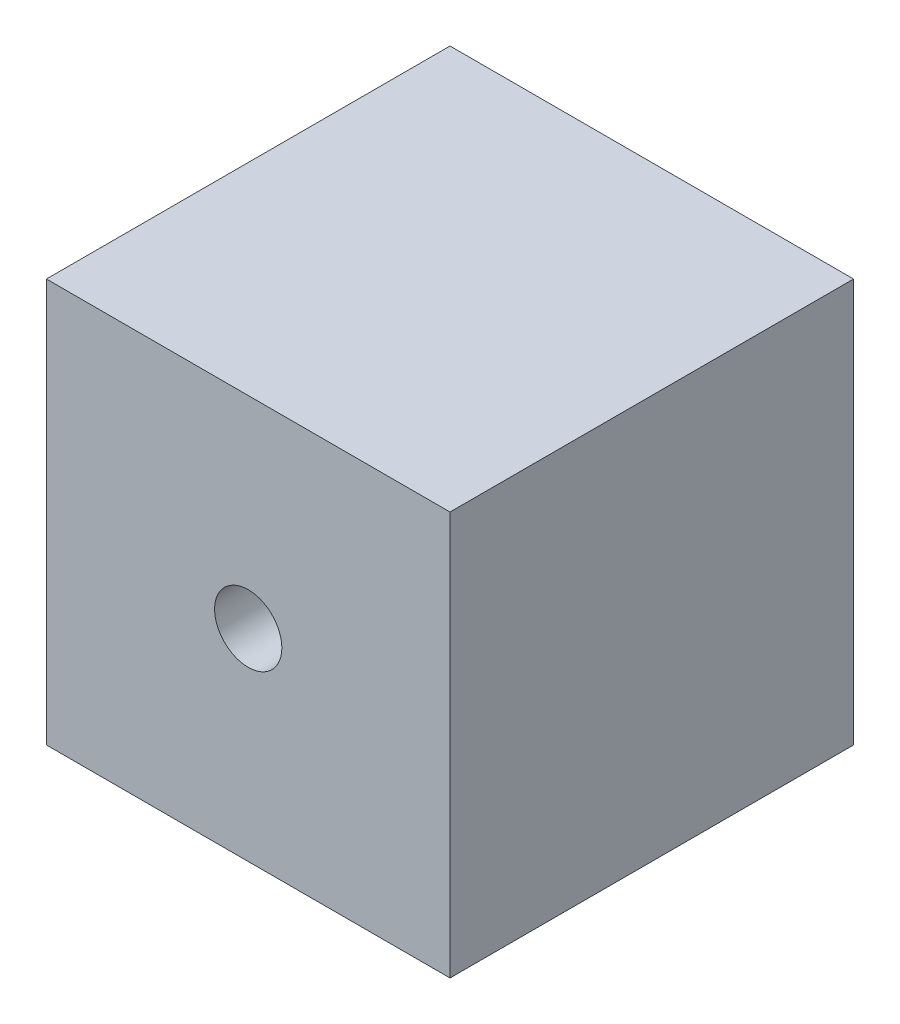
from build123d import *

# Parameters (mm, degrees)
SKETCH2_W           = 30
SKETCH2_H           = 30
BOSS_EXTRUDE1_DEPTH = 15
SKETCH3_R           = 2.5
CUT_EXTRUDE1_DEPTH  = 5


with BuildPart() as part:
    # Sketch2 → Boss-Extrude1 (new body, symmetric)
    with BuildSketch(Plane(origin=(0, 0, 0), x_dir=(0, 0, -1), z_dir=(1, 0, 0))):
        with Locations((15, 15)):
            Rectangle(SKETCH2_W, SKETCH2_H)
    extrude(amount=BOSS_EXTRUDE1_DEPTH, both=True)

    # Sketch3 → Cut-Extrude1 (cut, symmetric)
    with BuildSketch(Plane.XY):
        with Locations((0, 15)):
            Circle(SKETCH3_R)
    extrude(amount=CUT_EXTRUDE1_DEPTH, both=True, mode=Mode.SUBTRACT)


solid = part.part
